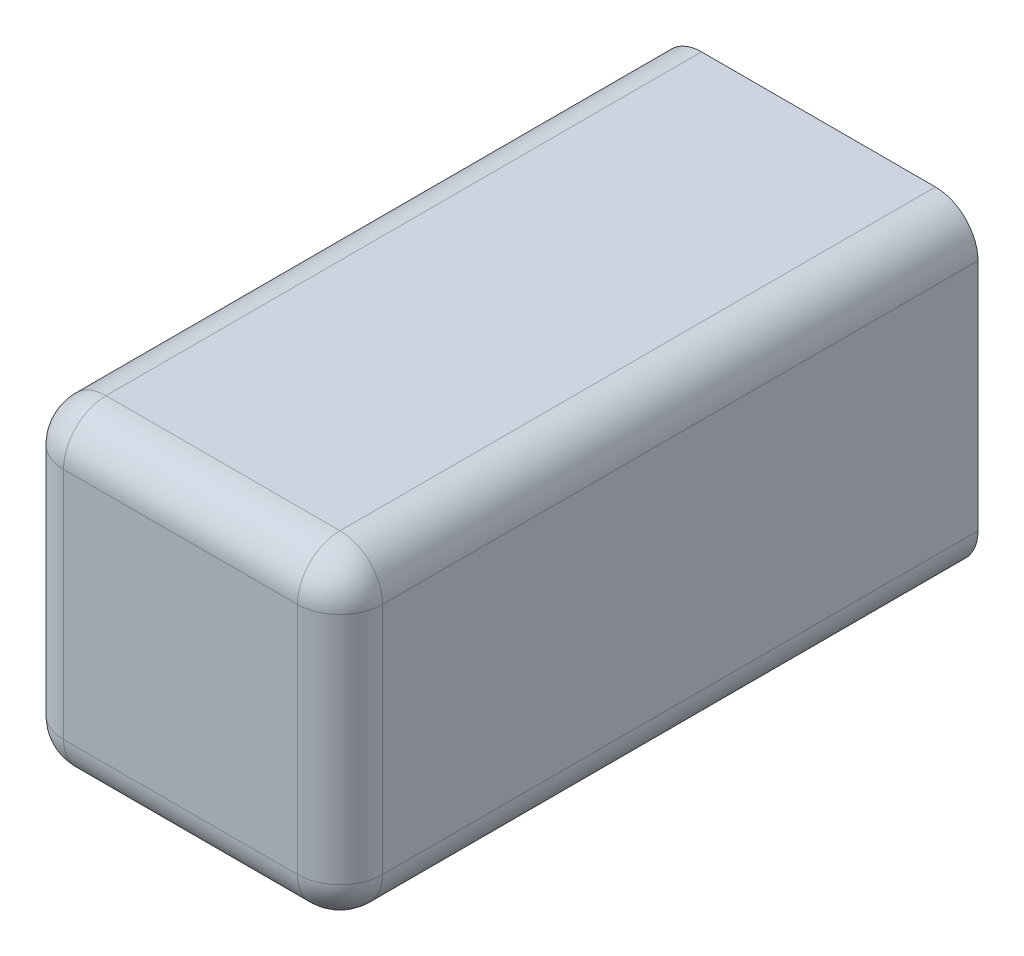
from build123d import *

# Parameters (mm, degrees)
SKETCH_1_W               = 15
SKETCH_1_H               = 15
EXTRUDE_1_DEPTH          = 30
SKETCH_2_W               = 7
SKETCH_2_H               = 7
CUT_EXTRUDE_1_DEPTH      = 25
CUT_EXTRUDE_1_DEPTH_BACK = 0.001
FILLET_1_R               = 2


with BuildPart() as part:
    # 草图1 → 凸台-拉伸1 (new body)
    with BuildSketch(Plane.XY):
        Rectangle(SKETCH_1_W, SKETCH_1_H)
    extrude(amount=EXTRUDE_1_DEPTH)

    # 草图2 → 切除-拉伸1 (cut, two sides)
    with BuildSketch(Plane.XY) as cut_extrude_1_sk:
        Rectangle(SKETCH_2_W, SKETCH_2_H)
    extrude(amount=CUT_EXTRUDE_1_DEPTH, mode=Mode.SUBTRACT)
    extrude(cut_extrude_1_sk.sketch, amount=-CUT_EXTRUDE_1_DEPTH_BACK, mode=Mode.SUBTRACT)

    # 圆角1
    fillet_1_edges = [part.edges().sort_by_distance(p)[0] for p in [
        (-7.5, 0, 30),
        (0, -7.5, 30),
        (7.5, 0, 30),
        (0, 7.5, 30),
        (7.5, -7.5, 15),
        (-7.5, -7.5, 15),
        (-7.5, 7.5, 15),
        (7.5, 7.5, 15),
    ]]
    fillet(fillet_1_edges, radius=FILLET_1_R)


solid = part.part
